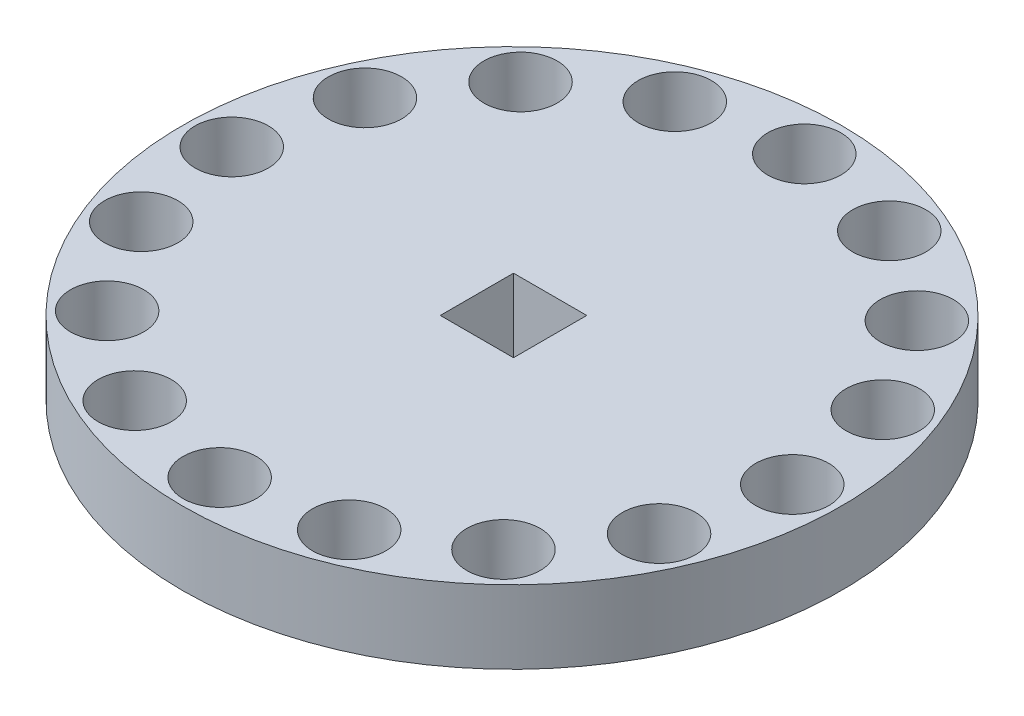
from build123d import *

# Parameters (mm, degrees)
SKIZZE1_R                       = 9
AUFSATZ_LINEAR_AUSTRAGEN1_DEPTH = 2
SKIZZE3_W                       = 2
SKIZZE3_H                       = 2
SCHNITT_LINEAR_AUSTRAGEN1_DEPTH = 3
SKIZZE4_R                       = 1
SCHNITT_LINEAR_AUSTRAGEN2_DEPTH = 3
KREISMUSTER1_COUNT              = 16


with BuildPart() as part:
    # Skizze1 → Aufsatz-Linear austragen1 (new body)
    with BuildSketch(Plane(origin=(0, 0, 0), x_dir=(1, 0, 0), z_dir=(0, 1, 0))):
        Circle(SKIZZE1_R)
    extrude(amount=AUFSATZ_LINEAR_AUSTRAGEN1_DEPTH)

    # Skizze3 → Schnitt-Linear austragen1 (cut)
    with BuildSketch(Plane(origin=(0, 2, 0), x_dir=(1, 0, 0), z_dir=(0, 1, 0))):
        with Locations((0.014205659, 0.027357499)):
            Rectangle(SKIZZE3_W, SKIZZE3_H)
    extrude(amount=-SCHNITT_LINEAR_AUSTRAGEN1_DEPTH, mode=Mode.SUBTRACT)

    # Skizze4 → Schnitt-Linear austragen2 (cut)
    with BuildSketch(Plane(origin=(0, 2, 0), x_dir=(1, 0, 0), z_dir=(0, 1, 0))):
        with Locations((7.817951829, -0.164692324)):
            Circle(SKIZZE4_R)
    schnitt_linear_austragen2 = extrude(amount=-SCHNITT_LINEAR_AUSTRAGEN2_DEPTH, mode=Mode.SUBTRACT)

    # Kreismuster1: Schnitt-Linear austragen2 ×16 about axis
    kreismuster1_axis = Axis((0, 0, 0), (0, 1, 0))
    for i in range(1, KREISMUSTER1_COUNT):
        add(schnitt_linear_austragen2.rotate(kreismuster1_axis, i * 360 / KREISMUSTER1_COUNT), mode=Mode.SUBTRACT)


solid = part.part
